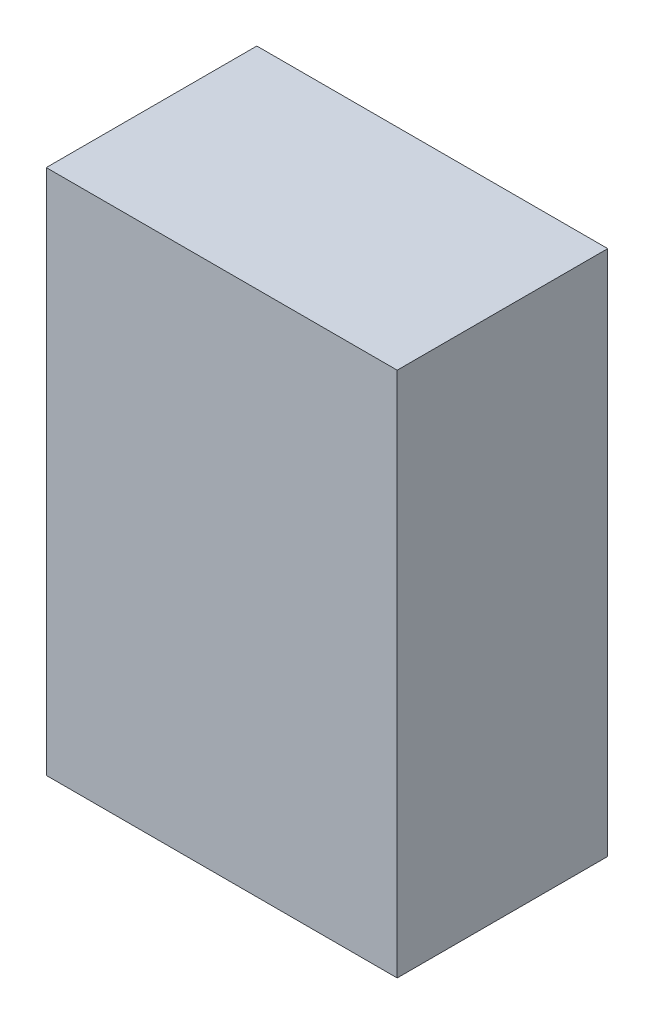
from build123d import *

# Parameters (mm, degrees)
SKETCH1_W           = 50.8
SKETCH1_H           = 30.48
BOSS_EXTRUDE1_DEPTH = 76.2


with BuildPart() as part:
    # Sketch1 → Boss-Extrude1 (new body)
    with BuildSketch(Plane(origin=(0, 0, 0), x_dir=(1, 0, 0), z_dir=(0, 1, 0))):
        with Locations((25.4, 15.24)):
            Rectangle(SKETCH1_W, SKETCH1_H)
    extrude(amount=BOSS_EXTRUDE1_DEPTH)


solid = part.part
